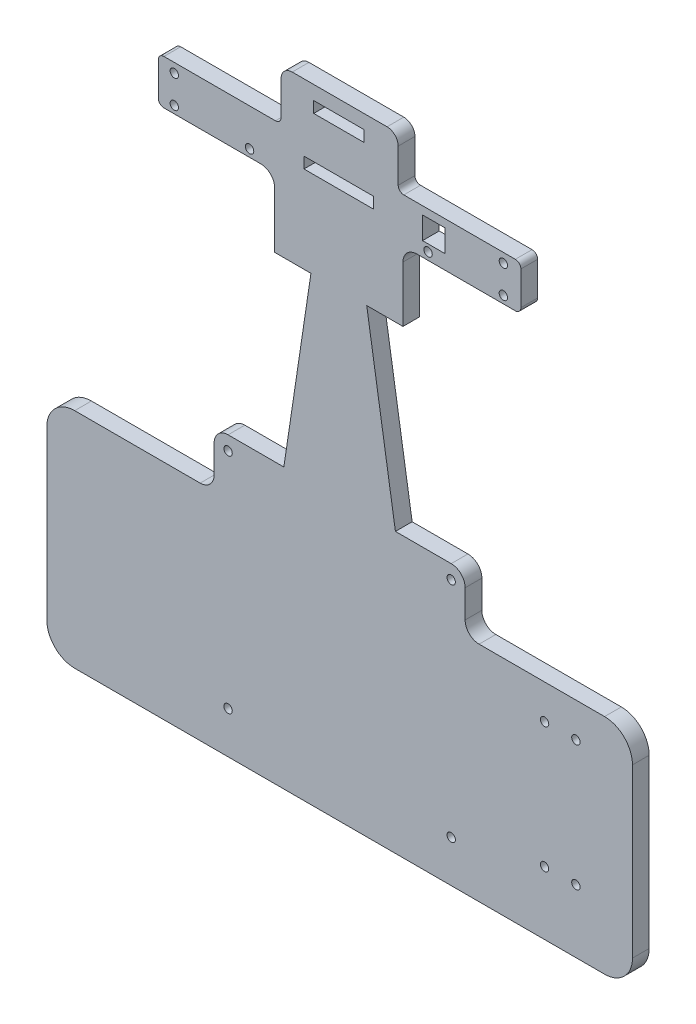
from build123d import *

# Parameters (mm, degrees)
SKETCH1_R           = 1.5
SKETCH1_W           = 8
SKETCH1_H           = 8
SKETCH1_W_2         = 25
SKETCH1_H_2         = 4
SKETCH1_W_3         = 18
BOSS_EXTRUDE3_DEPTH = 6
SKETCH1_9_R         = 1.5
CUT_EXTRUDE2_DEPTH  = 6


with BuildPart() as part:
    # Sketch1 → Boss-Extrude3 (new body)
    with BuildSketch(Plane.XY):
        with BuildLine():
            Line((-36.07279856, -10.151608153), (153.92720144, -10.151608153))
            ThreePointArc((153.92720144, -10.151608153), (160.998269252, -7.222675965), (163.92720144, -0.151608153))
            Line((163.92720144, -0.151608153), (163.92720144, 59.848391847))
            ThreePointArc((163.92720144, 59.848391847), (160.998269252, 66.919459659), (153.92720144, 69.848391847))
            Line((153.92720144, 69.848391847), (108.92720144, 69.848391847))
            ThreePointArc((108.92720144, 69.848391847), (105.391667534, 71.312857941), (103.92720144, 74.848391847))
            Line((103.92720144, 74.848391847), (103.92720144, 84.848391847))
            ThreePointArc((103.92720144, 84.848391847), (102.462735346, 88.383925753), (98.92720144, 89.848391847))
            Line((98.92720144, 89.848391847), (78.92720144, 89.848391847))
            Line((78.92720144, 89.848391847), (68.638210005, 154.848391847))
            Line((68.638210005, 154.848391847), (81.638210005, 154.848391847))
            Line((81.638210005, 154.848391847), (81.638210005, 174.848391847))
            ThreePointArc((81.638210005, 174.848391847), (83.102676099, 178.383925753), (86.638210005, 179.848391847))
            Line((86.638210005, 179.848391847), (121.92720144, 179.848391847))
            ThreePointArc((121.92720144, 179.848391847), (123.341415002, 180.434178284), (123.92720144, 181.848391847))
            Line((123.92720144, 181.848391847), (123.92720144, 193.848391847))
            ThreePointArc((123.92720144, 193.848391847), (123.341415002, 195.262605409), (121.92720144, 195.848391847))
            Line((121.92720144, 195.848391847), (81.92720144, 195.848391847))
            ThreePointArc((81.92720144, 195.848391847), (80.512987878, 196.434178284), (79.92720144, 197.848391847))
            Line((79.92720144, 197.848391847), (79.92720144, 210))
            ThreePointArc((79.92720144, 210), (78.755628565, 212.828427125), (75.92720144, 214))
            Line((75.92720144, 214), (41.92720144, 214))
            ThreePointArc((41.92720144, 214), (39.098774315, 212.828427125), (37.92720144, 210))
            Line((37.92720144, 210), (37.92720144, 197.848391847))
            ThreePointArc((37.92720144, 197.848391847), (37.341415002, 196.434178284), (35.92720144, 195.848391847))
            Line((35.92720144, 195.848391847), (-4.07279856, 195.848391847))
            ThreePointArc((-4.07279856, 195.848391847), (-5.487012122, 195.262605409), (-6.07279856, 193.848391847))
            Line((-6.07279856, 193.848391847), (-6.07279856, 181.848391847))
            ThreePointArc((-6.07279856, 181.848391847), (-5.487012122, 180.434178284), (-4.07279856, 179.848391847))
            Line((-4.07279856, 179.848391847), (30.638210005, 179.848391847))
            ThreePointArc((30.638210005, 179.848391847), (34.173743911, 178.383925753), (35.638210005, 174.848391847))
            Line((35.638210005, 174.848391847), (35.638210005, 154.848391847))
            Line((35.638210005, 154.848391847), (48.638210005, 154.848391847))
            Line((48.638210005, 154.848391847), (38.92720144, 89.848391847))
            Line((38.92720144, 89.848391847), (18.92720144, 89.848391847))
            ThreePointArc((18.92720144, 89.848391847), (15.391667534, 88.383925753), (13.92720144, 84.848391847))
            Line((13.92720144, 84.848391847), (13.92720144, 74.848391847))
            ThreePointArc((13.92720144, 74.848391847), (12.462735346, 71.312857941), (8.92720144, 69.848391847))
            Line((8.92720144, 69.848391847), (-36.07279856, 69.848391847))
            ThreePointArc((-36.07279856, 69.848391847), (-43.143866372, 66.919459659), (-46.07279856, 59.848391847))
            Line((-46.07279856, 59.848391847), (-46.07279856, -0.151608153))
            ThreePointArc((-46.07279856, -0.151608153), (-43.143866372, -7.222675965), (-36.07279856, -10.151608153))
        make_face()
        with Locations((143.638210005, 57.5)):
            Circle(SKETCH1_R, mode=Mode.SUBTRACT)
        with Locations((132.413840271, 57.5)):
            Circle(SKETCH1_R, mode=Mode.SUBTRACT)
        with Locations((132.413840271, 12.5)):
            Circle(SKETCH1_R, mode=Mode.SUBTRACT)
        with Locations((143.638210005, 12.5)):
            Circle(SKETCH1_R, mode=Mode.SUBTRACT)
        with Locations((117.638210005, 182.5)):
            Circle(SKETCH1_R, mode=Mode.SUBTRACT)
        with Locations((117.638210005, 192.5)):
            Circle(SKETCH1_R, mode=Mode.SUBTRACT)
        with Locations((-0.361789995, 182.5)):
            Circle(SKETCH1_R, mode=Mode.SUBTRACT)
        with Locations((-0.361789995, 192.5)):
            Circle(SKETCH1_R, mode=Mode.SUBTRACT)
        with Locations((26.638210005, 182.5)):
            Circle(SKETCH1_R, mode=Mode.SUBTRACT)
        with Locations((90.638210005, 182.5)):
            Circle(SKETCH1_R, mode=Mode.SUBTRACT)
        with Locations((92.638210005, 189)):
            Rectangle(SKETCH1_W, SKETCH1_H, mode=Mode.SUBTRACT)
        with Locations((58.638210005, 188)):
            Rectangle(SKETCH1_W_2, SKETCH1_H_2, mode=Mode.SUBTRACT)
        with Locations((58.638210005, 207)):
            Rectangle(SKETCH1_W_3, SKETCH1_H_2, mode=Mode.SUBTRACT)
    extrude(amount=-BOSS_EXTRUDE3_DEPTH)

    # Sketch1_9 → Cut-Extrude2 (cut)
    with BuildSketch(Plane.XY):
        with Locations((98.92720144, 84.848391847)):
            Circle(SKETCH1_9_R)
        with Locations((18.92720144, 84.848391847)):
            Circle(SKETCH1_9_R)
        with Locations((98.92720144, 4.848391847)):
            Circle(SKETCH1_9_R)
        with Locations((18.92720144, 4.848391847)):
            Circle(SKETCH1_9_R)
    extrude(amount=-CUT_EXTRUDE2_DEPTH, mode=Mode.SUBTRACT)


solid = part.part
